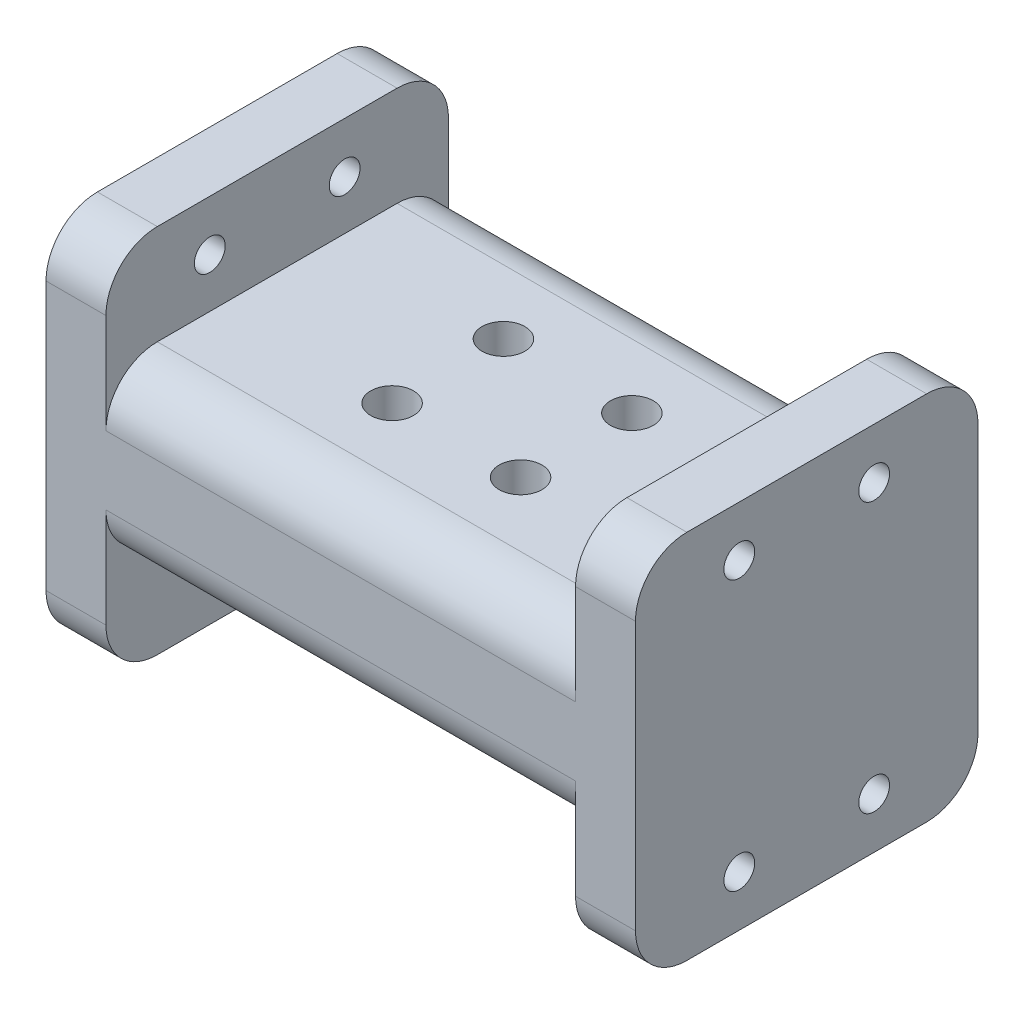
from build123d import *

# Parameters (mm, degrees)
SKETCH1_W           = 50.8
SKETCH1_H           = 55
SKETCH1_R           = 2.286
BOSS_EXTRUDE1_DEPTH = 8.89
FILLET1_R           = 7.62
SKETCH2_W           = 50.8
SKETCH2_H           = 25.4
BOSS_EXTRUDE2_DEPTH = 34.81959
FILLET2_R           = 7.62
SKETCH3_R           = 3.175
CUT_EXTRUDE1_DEPTH  = 41.2
LPATTERN1_COUNT     = 2
LPATTERN1_PITCH     = 16.51


with BuildPart() as part:
    # Sketch1 → Boss-Extrude1 (new body)
    with BuildSketch(Plane(origin=(0, 0, 0), x_dir=(0, 0, -1), z_dir=(1, 0, 0))):
        Rectangle(SKETCH1_W, SKETCH1_H)
        with Locations((-10, 20)):
            Circle(SKETCH1_R, mode=Mode.SUBTRACT)
        with Locations((10, 20)):
            Circle(SKETCH1_R, mode=Mode.SUBTRACT)
        with Locations((-10, -20)):
            Circle(SKETCH1_R, mode=Mode.SUBTRACT)
        with Locations((10, -20)):
            Circle(SKETCH1_R, mode=Mode.SUBTRACT)
    extrude(amount=BOSS_EXTRUDE1_DEPTH)

    # Fillet1
    fillet1_edges = [part.edges().sort_by_distance(p)[0] for p in [
        (4.445, 27.5, 25.4),
        (4.445, 27.5, -25.4),
        (4.445, -27.5, -25.4),
        (4.445, -27.5, 25.4),
    ]]
    fillet(fillet1_edges, radius=FILLET1_R)

    # Sketch2 → Boss-Extrude2 (add)
    with BuildSketch(Plane(origin=(8.89, 0, 0), x_dir=(0, 0, -1), z_dir=(1, 0, 0))):
        Rectangle(SKETCH2_W, SKETCH2_H)
    extrude(amount=BOSS_EXTRUDE2_DEPTH)

    # Fillet2
    fillet2_edges = [part.edges().sort_by_distance(p)[0] for p in [
        (26.299795, 12.7, 25.4),
        (26.299795, -12.7, 25.4),
        (26.299795, -12.7, -25.4),
        (26.299795, 12.7, -25.4),
    ]]
    fillet(fillet2_edges, radius=FILLET2_R)

    # Mirror6: part across plane


with BuildPart() as part_1:
    add(part.part)
    add(part.part.mirror(Plane(origin=(43.70959, 0, 0), x_dir=(0, 0, 1), z_dir=(1, 0, 0))))

    # Sketch3 → Cut-Extrude1 (cut, through all)
    with BuildSketch(Plane(origin=(0, 12.7, 0), x_dir=(1, 0, 0), z_dir=(0, 1, 0))):
        with Locations((53.23459, 8.255)):
            Circle(SKETCH3_R)
        with Locations((34.18459, 8.255)):
            Circle(SKETCH3_R)
    cut_extrude1 = extrude(amount=-CUT_EXTRUDE1_DEPTH, mode=Mode.SUBTRACT)

    # LPattern1: Cut-Extrude1 ×2
    with Locations(*[(0, 0, i * LPATTERN1_PITCH) for i in range(1, LPATTERN1_COUNT)]):
        add(cut_extrude1, mode=Mode.SUBTRACT)


solid = part_1.part
